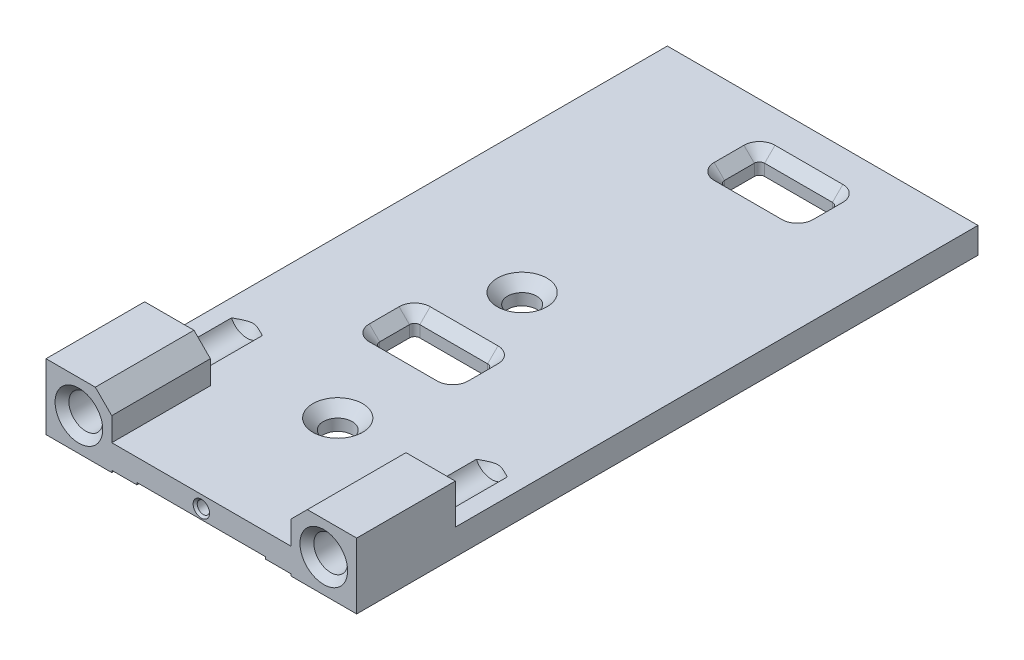
from build123d import *

# Parameters (mm, degrees)
SKETCH1_W                                 = 60
SKETCH1_H                                 = 120
BOSS_EXTRUDE1_DEPTH                       = 12.7
SKETCH2_W                                 = 34.6
SKETCH2_H                                 = 7.7
CUT_EXTRUDE1_DEPTH                        = 121
F_3_32_0_09375_DIAMETER_HOLE1_D           = 2.38125
F_3_32_0_09375_DIAMETER_HOLE1_DEPTH       = 19.05
F_3_32_0_09375_DIAMETER_HOLE1_CSINK_D     = 3.175
F_3_32_0_09375_DIAMETER_HOLE1_CSINK_ANGLE = 90
F_3_32_0_09375_DIAMETER_HOLE1_TIP         = 0.715399675
CUT_EXTRUDE2_DEPTH                        = 1
CUT_EXTRUDE2_DEPTH_BACK                   = 121
F_5_16_18_TAPPED_HOLE1_D                  = 6.5278
F_5_16_18_TAPPED_HOLE1_DEPTH              = 32.45
F_5_16_18_TAPPED_HOLE1_CSINK_D            = 9.2075
F_5_16_18_TAPPED_HOLE1_CSINK_ANGLE        = 90
F_5_16_18_TAPPED_HOLE1_TIP                = 1.961148974
CHAMFER1_SIZE                             = 3.175
SKETCH6_W                                 = 15.1
SKETCH6_H                                 = 7.75
CUT_EXTRUDE3_DEPTH                        = 6
FILLET1_R                                 = 1
SKETCH7_R                                 = 2.8
CUT_EXTRUDE4_DEPTH                        = 6.0000001
CHAMFER2_SIZE                             = 2
SKETCH10_W                                = 60
SKETCH10_H                                = 100.95
CUT_EXTRUDE5_DEPTH                        = 7.7
SKETCH12_W                                = 24.87086649
SKETCH12_H                                = 0.4
CUT_EXTRUDE11_DEPTH                       = 121.0000001
SKETCH13_W                                = 34.6
SKETCH13_H                                = 0.374910819
CUT_EXTRUDE12_DEPTH                       = 121


with BuildPart() as part:
    # Sketch1 → Boss-Extrude1 (new body)
    with BuildSketch(Plane(origin=(0, 0, 0), x_dir=(1, 0, 0), z_dir=(0, 1, 0))):
        with Locations((0, 60)):
            Rectangle(SKETCH1_W, SKETCH1_H)
    extrude(amount=BOSS_EXTRUDE1_DEPTH)

    # Sketch2 → Cut-Extrude1 (cut, through all)
    with BuildSketch(Plane.XY):
        with Locations((0, 8.85)):
            Rectangle(SKETCH2_W, SKETCH2_H)
    extrude(amount=-CUT_EXTRUDE1_DEPTH, mode=Mode.SUBTRACT)

    # 3_32 _0.09375_ Diameter Hole1
    with Locations(Plane.XY):
        with Locations((0, 2.61875)):
            CounterSinkHole(F_3_32_0_09375_DIAMETER_HOLE1_D / 2, F_3_32_0_09375_DIAMETER_HOLE1_CSINK_D / 2, depth=F_3_32_0_09375_DIAMETER_HOLE1_DEPTH, counter_sink_angle=F_3_32_0_09375_DIAMETER_HOLE1_CSINK_ANGLE)
            with Locations((0, 0, -(F_3_32_0_09375_DIAMETER_HOLE1_DEPTH + F_3_32_0_09375_DIAMETER_HOLE1_TIP / 2))):  # 118° drill point
                Cone(0, F_3_32_0_09375_DIAMETER_HOLE1_D / 2, F_3_32_0_09375_DIAMETER_HOLE1_TIP, mode=Mode.SUBTRACT)

    # Sketch3 → Cut-Extrude2 (cut, two sides)
    with BuildSketch(Plane.XY) as cut_extrude2_sk:
        with BuildLine():
            Line((-124.818289263, -9.651397294), (-17.3, 0))
            ThreePointArc((-17.3, 0), (0, 0.774910819), (17.3, 0))
            Line((17.3, 0), (124.818289263, -9.651397294))
            Line((124.818289263, -9.651397294), (124.818289263, -225.552596882))
            Line((124.818289263, -225.552596882), (-124.818289263, -225.552596882))
            Line((-124.818289263, -225.552596882), (-124.818289263, -9.651397294))
        make_face()
    extrude(amount=CUT_EXTRUDE2_DEPTH, mode=Mode.SUBTRACT)
    extrude(cut_extrude2_sk.sketch, amount=-CUT_EXTRUDE2_DEPTH_BACK, mode=Mode.SUBTRACT)

    # 5_16-18 Tapped Hole1
    with Locations(Plane.XY):
        with Locations((-23.65, 6.35), (23.65, 6.35)):
            CounterSinkHole(F_5_16_18_TAPPED_HOLE1_D / 2, F_5_16_18_TAPPED_HOLE1_CSINK_D / 2, depth=F_5_16_18_TAPPED_HOLE1_DEPTH, counter_sink_angle=F_5_16_18_TAPPED_HOLE1_CSINK_ANGLE)
            with Locations((0, 0, -(F_5_16_18_TAPPED_HOLE1_DEPTH + F_5_16_18_TAPPED_HOLE1_TIP / 2))):  # 118° drill point
                Cone(0, F_5_16_18_TAPPED_HOLE1_D / 2, F_5_16_18_TAPPED_HOLE1_TIP, mode=Mode.SUBTRACT)

    # Chamfer1
    chamfer1_edges = [part.edges().sort_by_distance(p)[0] for p in [
        (-17.3, 12.7, -60),
        (17.3, 12.7, -60),
    ]]
    chamfer(chamfer1_edges, length=CHAMFER1_SIZE)

    # Sketch6 → Cut-Extrude3 (cut, through all)
    with BuildSketch(Plane(origin=(0, 5, 0), x_dir=(1, 0, 0), z_dir=(0, 1, 0))):
        with Locations((3.55, 107.9216)):
            Rectangle(SKETCH6_W, SKETCH6_H)
        with Locations((-2.75, 47.6216)):
            Rectangle(SKETCH6_W, SKETCH6_H)
    extrude(amount=-CUT_EXTRUDE3_DEPTH, mode=Mode.SUBTRACT)

    # Fillet1
    fillet1_edges = [part.edges().sort_by_distance(p)[0] for p in [
        (11.1, 2.72813819, -111.7966),
        (11.1, 2.72813819, -104.0466),
        (-4, 2.866781366, -104.0466),
        (-4, 2.866781366, -111.7966),
        (4.8, 2.857683387, -51.4966),
        (4.8, 2.857683387, -43.7466),
        (-10.3, 2.750290995, -43.7466),
        (-10.3, 2.750290995, -51.4966),
    ]]
    fillet(fillet1_edges, radius=FILLET1_R)

    # Sketch7 → Cut-Extrude4 (cut, through all)
    with BuildSketch(Plane(origin=(0, 5, 0), x_dir=(1, 0, 0), z_dir=(0, 1, 0))):
        with Locations(Location((-2.8, 64.7568, 0), (0, 0, 270))):  # turned: the seam where the file's is
            Circle(SKETCH7_R)
        with Locations(Location((0.3851, 25.9568, 0), (0, 0, 270))):  # turned: the seam where the file's is
            Circle(SKETCH7_R)
    extrude(amount=-CUT_EXTRUDE4_DEPTH, mode=Mode.SUBTRACT)

    # Chamfer2
    chamfer2_edges = [part.edges().sort_by_distance(p)[0] for p in [
        (3.55, 5, -104.0466),
        (-4, 5, -107.9216),
        (11.1, 5, -107.9216),
        (3.55, 5, -111.7966),
        (-2.75, 5, -51.4966),
        (4.8, 5, -47.6216),
        (-2.75, 5, -43.7466),
        (-10.3, 5, -47.6216),
        (-3.707106781, 5, -104.339493219),
        (10.807106781, 5, -104.339493219),
        (10.807106781, 5, -111.503706781),
        (4.507106781, 5, -51.203706781),
        (4.507106781, 5, -44.039493219),
        (-10.007106781, 5, -44.039493219),
        (-10.007106781, 5, -51.203706781),
        (-3.707106781, 5, -111.503706781),
        (-2.8, 5, -67.5568),
        (0.3851, 5, -28.7568),
    ]]
    chamfer(chamfer2_edges, length=CHAMFER2_SIZE)

    # Sketch10 → Cut-Extrude5 (cut)
    with BuildSketch(Plane(origin=(0, 12.7, 0), x_dir=(1, 0, 0), z_dir=(0, 1, 0))):
        with Locations((0, 69.525)):
            Rectangle(SKETCH10_W, SKETCH10_H)
    extrude(amount=-CUT_EXTRUDE5_DEPTH, mode=Mode.SUBTRACT)

    # Sketch12 → Cut-Extrude11 (cut, through all)
    with BuildSketch(Plane.XY):
        with Locations((0, 0.574910819)):
            Rectangle(SKETCH12_W, SKETCH12_H)
    extrude(amount=-CUT_EXTRUDE11_DEPTH, mode=Mode.SUBTRACT)

    # Sketch13 → Cut-Extrude12 (cut, through all)
    with BuildSketch(Plane.XY):
        with Locations((0, 0.18745541)):
            Rectangle(SKETCH13_W, SKETCH13_H)
    extrude(amount=-CUT_EXTRUDE12_DEPTH, mode=Mode.SUBTRACT)


solid = part.part
